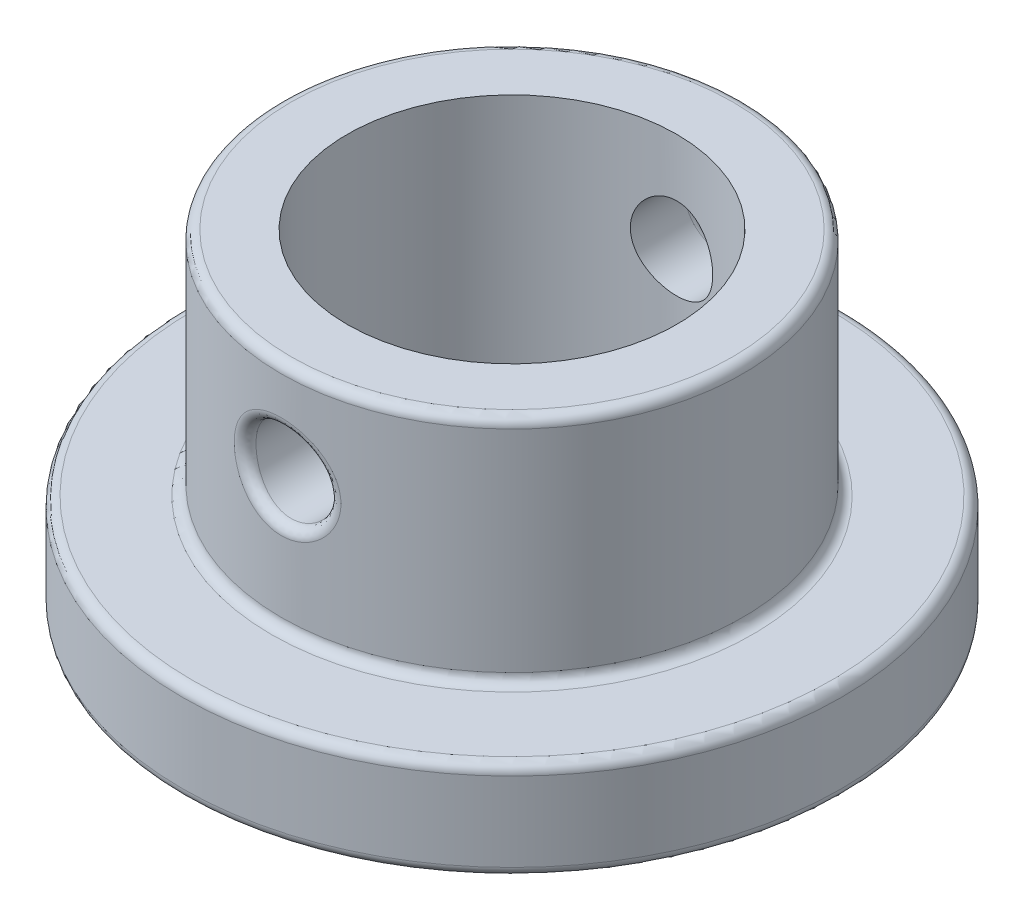
from build123d import *

# Parameters (mm, degrees)
SKETCH1_R               = 10
SKETCH1_R_2             = 5
BOSS_EXTRUDE1_DEPTH     = 3
SKETCH2_R               = 7
SKETCH2_R_2             = 5
BOSS_EXTRUDE2_DEPTH     = 7
SKETCH3_R               = 1.25
CUT_EXTRUDE1_DEPTH      = 11
CUT_EXTRUDE1_DEPTH_BACK = 11
FILLET1_R               = 0.3


with BuildPart() as part:
    # Sketch1 → Boss-Extrude1 (new body)
    with BuildSketch(Plane(origin=(0, 0, 0), x_dir=(1, 0, 0), z_dir=(0, 1, 0))):
        Circle(SKETCH1_R)
        Circle(SKETCH1_R_2, mode=Mode.SUBTRACT)
    extrude(amount=BOSS_EXTRUDE1_DEPTH)

    # Sketch2 → Boss-Extrude2 (add)
    with BuildSketch(Plane(origin=(0, 3, 0), x_dir=(1, 0, 0), z_dir=(0, 1, 0))):
        Circle(SKETCH2_R)
        Circle(SKETCH2_R_2, mode=Mode.SUBTRACT)
    extrude(amount=BOSS_EXTRUDE2_DEPTH)

    # Sketch3 → Cut-Extrude1 (cut, two sides)
    with BuildSketch(Plane.XY) as cut_extrude1_sk:
        with Locations((0, 7)):
            Circle(SKETCH3_R)
    extrude(amount=CUT_EXTRUDE1_DEPTH, mode=Mode.SUBTRACT)
    extrude(cut_extrude1_sk.sketch, amount=-CUT_EXTRUDE1_DEPTH_BACK, mode=Mode.SUBTRACT)

    # Fillet1
    fillet1_edges = [part.edges().sort_by_distance(p)[0] for p in [
        (-7, 10, 0),
        (-7, 3, 0),
        (-1.250000002, 6.999999998, -6.887488659),
        (-1.250000002, 6.999999998, 6.887488659),
        (-10, 0, 0),
        (-10, 3, 0),
    ]]
    fillet(fillet1_edges, radius=FILLET1_R)


solid = part.part
